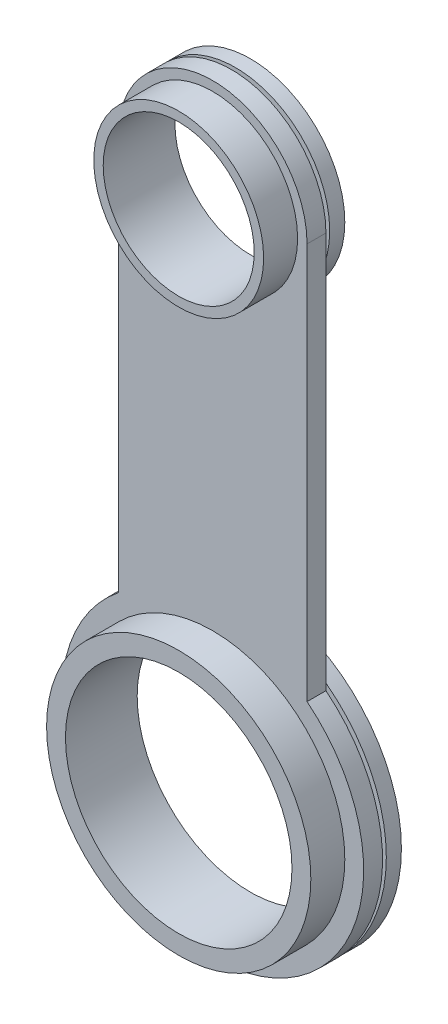
from build123d import *

# Parameters (mm, degrees)
CROQUIS1_R              = 6
CROQUIS1_R_2            = 4
SALIENTE_EXTRUIR1_DEPTH = 1
CROQUIS2_R              = 7
CROQUIS2_R_2            = 6
CROQUIS2_R_3            = 4.5
CROQUIS2_R_4            = 4
SALIENTE_EXTRUIR2_DEPTH = 1.8
CROQUIS3_R              = 7
CROQUIS3_R_2            = 6
CROQUIS3_R_3            = 4.5
CROQUIS3_R_4            = 4
SALIENTE_EXTRUIR3_DEPTH = 0.2
CROQUIS4_R              = 7.99896204
CROQUIS4_R_2            = 6
CROQUIS4_R_3            = 5
CROQUIS4_R_4            = 4
SALIENTE_EXTRUIR4_DEPTH = 0.8


with BuildPart() as part:
    # Croquis1 → Saliente-Extruir1 (new body)
    with BuildSketch(Plane.XY):
        with BuildLine():
            Line((-10, -12.938825758), (-10, -33.938825758))
            ThreePointArc((-10, -33.938825758), (-5, -48.183823756), (0, -33.938825758))
            Line((0, -33.938825758), (0, -12.938825758))
            ThreePointArc((0, -12.938825758), (-5, -7.938825758), (-10, -12.938825758))
        make_face()
        with Locations((-5, -40.183823756)):
            Circle(CROQUIS1_R, mode=Mode.SUBTRACT)
        with Locations((-5, -12.938825758)):
            Circle(CROQUIS1_R_2, mode=Mode.SUBTRACT)
    extrude(amount=SALIENTE_EXTRUIR1_DEPTH)

    # Croquis2 → Saliente-Extruir2 (add)
    with BuildSketch(Plane.XY.offset(1)):
        with Locations((-5, -40.183823756)):
            Circle(CROQUIS2_R)
        with Locations((-5, -40.183823756)):
            Circle(CROQUIS2_R_2, mode=Mode.SUBTRACT)
        with Locations((-5, -12.938825758)):
            Circle(CROQUIS2_R_3)
        with Locations((-5, -12.938825758)):
            Circle(CROQUIS2_R_4, mode=Mode.SUBTRACT)
    extrude(amount=SALIENTE_EXTRUIR2_DEPTH)

    # Croquis3 → Saliente-Extruir3 (add)
    with BuildSketch(Plane(origin=(0, 0, 0), x_dir=(-1, 0, 0), z_dir=(0, 0, -1))):
        with Locations((5, -40.183823756)):
            Circle(CROQUIS3_R)
        with Locations((5, -40.183823756)):
            Circle(CROQUIS3_R_2, mode=Mode.SUBTRACT)
        with Locations((5, -12.938825758)):
            Circle(CROQUIS3_R_3)
        with Locations((5, -12.938825758)):
            Circle(CROQUIS3_R_4, mode=Mode.SUBTRACT)
    extrude(amount=SALIENTE_EXTRUIR3_DEPTH)

    # Croquis4 → Saliente-Extruir4 (add)
    with BuildSketch(Plane(origin=(0, 0, -0.2), x_dir=(-1, 0, 0), z_dir=(0, 0, -1))):
        with Locations((5, -40.183823756)):
            Circle(CROQUIS4_R)
        with Locations((5, -40.183823756)):
            Circle(CROQUIS4_R_2, mode=Mode.SUBTRACT)
        with Locations((5, -12.938825758)):
            Circle(CROQUIS4_R_3)
        with Locations((5, -12.938825758)):
            Circle(CROQUIS4_R_4, mode=Mode.SUBTRACT)
    extrude(amount=SALIENTE_EXTRUIR4_DEPTH)


solid = part.part
